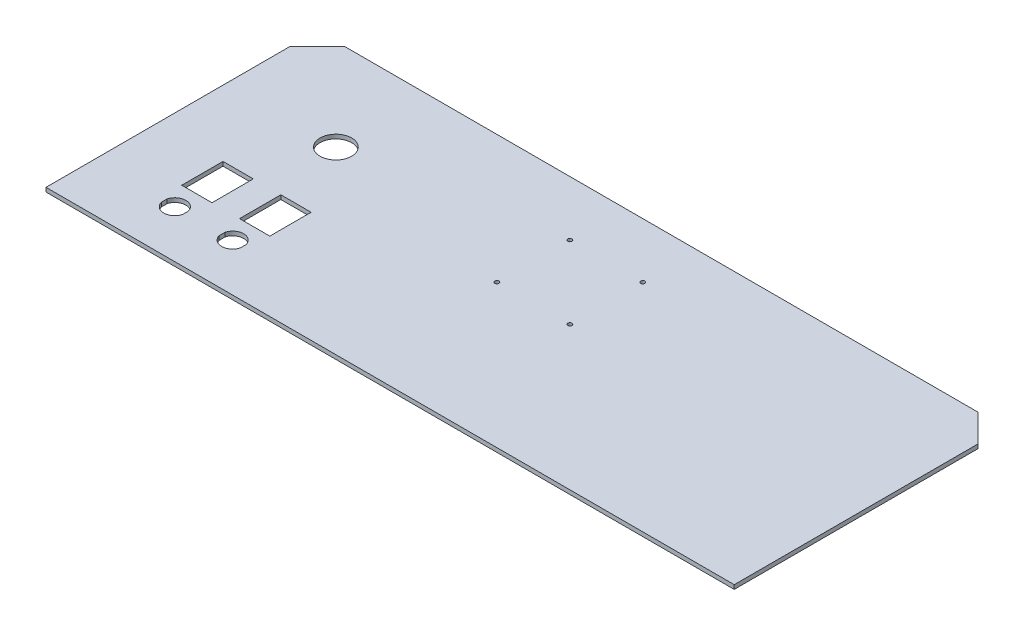
from build123d import *

# Parameters (mm, degrees)
BOSS_EXTRUDE1_DEPTH = 3
SKETCH2_R           = 1.5
CUT_EXTRUDE1_DEPTH  = 3
SKETCH3_R           = 11.5
SKETCH3_W           = 22
SKETCH3_H           = 30
CUT_EXTRUDE2_DEPTH  = 3
CUT_EXTRUDE3_DEPTH  = 3


with BuildPart() as part:
    # Sketch1 → Boss-Extrude1 (new body)
    with BuildSketch(Plane(origin=(0, 0, 0), x_dir=(1, 0, 0), z_dir=(0, 1, 0))):
        Polygon((219.069498766, 78.55), (219.069498766, -98.55), (-280.930501234, -98.55), (-280.930501234, 78.55), (-260.930501234, 98.55), (199.069498766, 98.55), align=None)
    extrude(amount=BOSS_EXTRUDE1_DEPTH)

    # Sketch2 → Cut-Extrude1 (cut)
    with BuildSketch(Plane(origin=(0, 3, 0), x_dir=(1, 0, 0), z_dir=(0, 1, 0))):
        with Locations((-4.430501234, 5.55)):
            Circle(SKETCH2_R)
        with Locations((-57.430501234, 5.55)):
            Circle(SKETCH2_R)
        with Locations((-57.430501234, 58.55)):
            Circle(SKETCH2_R)
        with Locations((-4.430501234, 58.55)):
            Circle(SKETCH2_R)
    extrude(amount=-CUT_EXTRUDE1_DEPTH, mode=Mode.SUBTRACT)

    # Sketch3 → Cut-Extrude2 (cut)
    with BuildSketch(Plane(origin=(0, 3, 0), x_dir=(1, 0, 0), z_dir=(0, 1, 0))):
        with Locations((-200.930501234, 32.05)):
            Circle(SKETCH3_R)
        with Locations((-221.930501234, -32.95)):
            Rectangle(SKETCH3_W, SKETCH3_H)
        with Locations((-179.930501234, -32.95)):
            Rectangle(SKETCH3_W, SKETCH3_H)
    extrude(amount=-CUT_EXTRUDE2_DEPTH, mode=Mode.SUBTRACT)

    # Sketch4 → Cut-Extrude3 (cut)
    with BuildSketch(Plane(origin=(0, 3, 0), x_dir=(1, 0, 0), z_dir=(0, 1, 0))):
        with BuildLine():
            Line((-187.630501234, -61.779746559), (-187.630501234, -66.120253441))
            ThreePointArc((-187.630501234, -66.120253441), (-179.930501234, -71.95), (-172.230501234, -66.120253441))
            Line((-172.230501234, -66.120253441), (-172.230501234, -61.779746559))
            ThreePointArc((-172.230501234, -61.779746559), (-179.930501234, -55.95), (-187.630501234, -61.779746559))
        make_face()
        with BuildLine():
            Line((-229.630501234, -61.779746559), (-229.630501234, -66.120253441))
            ThreePointArc((-229.630501234, -66.120253441), (-221.930501234, -71.95), (-214.230501234, -66.120253441))
            Line((-214.230501234, -66.120253441), (-214.230501234, -61.779746559))
            ThreePointArc((-214.230501234, -61.779746559), (-221.930501234, -55.95), (-229.630501234, -61.779746559))
        make_face()
    extrude(amount=-CUT_EXTRUDE3_DEPTH, mode=Mode.SUBTRACT)


solid = part.part
